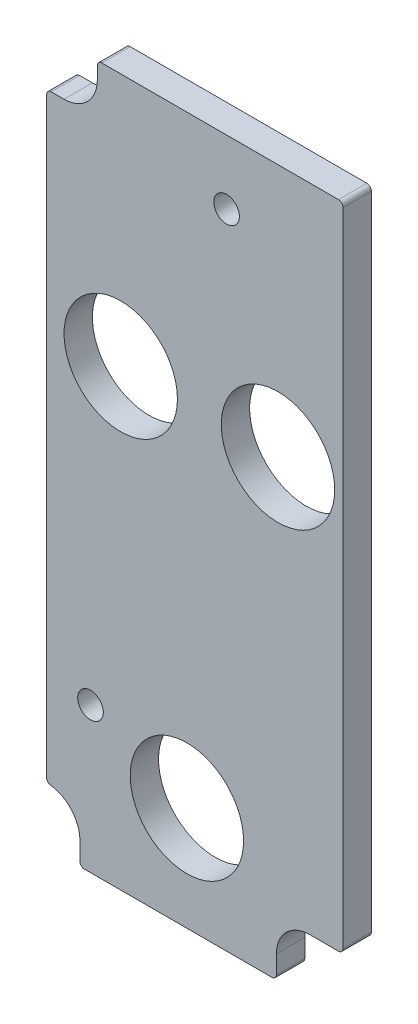
from build123d import *

# Parameters (mm, degrees)
BOSS_EXTRUDE1_DEPTH         = 4.7625
F_3_4_0_75_DIAMETER_HOLE1_D = 19.05
F_6_CLEARANCE_HOLE1_D       = 4.3053


with BuildPart() as part:
    # Sketch1 → Boss-Extrude1 (new body)
    with BuildSketch(Plane.XY):
        with BuildLine():
            Line((-0.762, 22.86), (-0.762, 130.683))
            ThreePointArc((-0.762, 130.683), (-0.985184633, 131.221815367), (-1.524, 131.445))
            Line((-1.524, 131.445), (-41.275, 131.445))
            ThreePointArc((-41.275, 131.445), (-41.813815367, 131.221815367), (-42.037, 130.683))
            Line((-42.037, 130.683), (-42.037, 128.5875))
            ThreePointArc((-42.037, 128.5875), (-43.673687307, 124.636187307), (-47.625, 122.9995))
            Line((-47.625, 122.9995), (-49.784, 122.9995))
            ThreePointArc((-49.784, 122.9995), (-50.322815367, 122.776315367), (-50.546, 122.2375))
            Line((-50.546, 122.2375), (-50.546, 22.814114212))
            ThreePointArc((-50.546, 22.814114212), (-50.354228586, 22.308660594), (-49.87544, 22.057620507))
            ThreePointArc((-49.87544, 22.057620507), (-46.364323705, 20.216659866), (-44.958, 16.51))
            Line((-44.958, 16.51), (-44.958, 13.462))
            ThreePointArc((-44.958, 13.462), (-44.734815367, 12.923184633), (-44.196, 12.7))
            Line((-44.196, 12.7), (-12.7, 12.7))
            ThreePointArc((-12.7, 12.7), (-12.161184633, 12.923184633), (-11.938, 13.462))
            Line((-11.938, 13.462), (-11.938, 16.51))
            ThreePointArc((-11.938, 16.51), (-10.301312693, 20.461312693), (-6.35, 22.098))
            Line((-6.35, 22.098), (-1.524, 22.098))
            ThreePointArc((-1.524, 22.098), (-0.985184633, 22.321184633), (-0.762, 22.86))
        make_face()
    extrude(amount=BOSS_EXTRUDE1_DEPTH)

    # 3/4 (0.75) Diameter Hole1 (through all)
    with Locations(Plane.XY.offset(4.7625)):
        with Locations((-38.1, 88.9), (-11.684, 88.9), (-26.9875, 30.1625)):
            Hole(F_3_4_0_75_DIAMETER_HOLE1_D / 2)

    # #6 Clearance Hole1 (through all)
    with Locations(Plane.XY.offset(4.7625)):
        with Locations((-20.32, 120.65), (-43.18, 37.084)):
            Hole(F_6_CLEARANCE_HOLE1_D / 2)


solid = part.part
